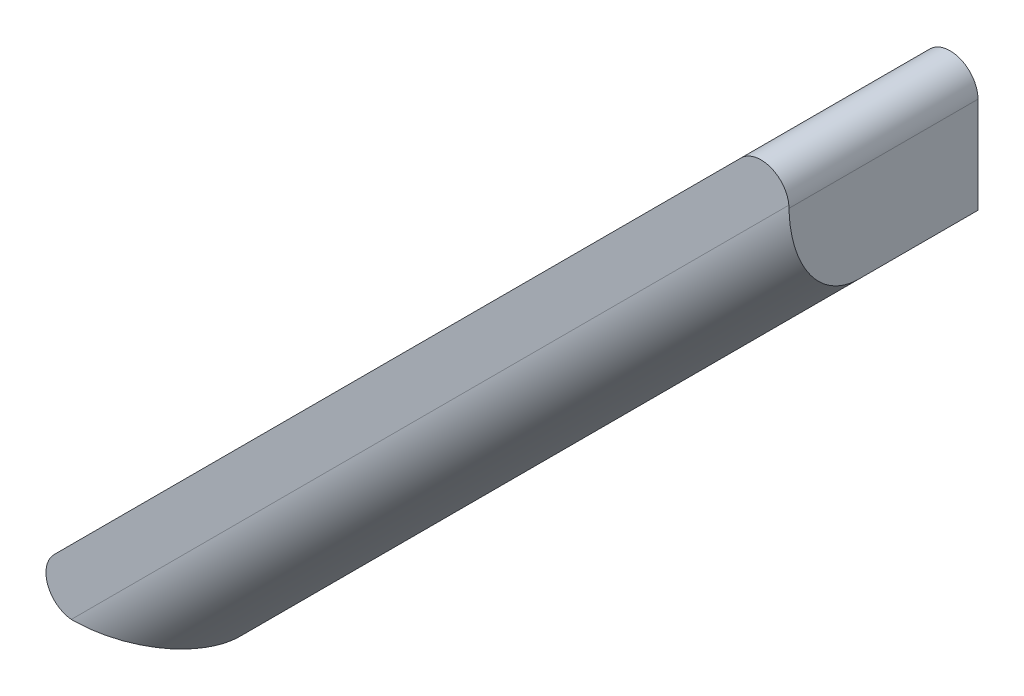
from build123d import *

# Parameters (mm, degrees)
EXTRUDE_1_DEPTH = 13.5
FILLET_1_R      = 2
FILLET_2_R      = 2
FILLET_3_R      = 5


with BuildPart() as part:
    # 草图1 → 凸台-拉伸1 (new body)
    with BuildSketch(Plane.XY):
        Polygon((0, 0), (0, -11.7), (-44.194173824, -55.894173824), (-55.894173824, -55.894173824), align=None)
    extrude(amount=EXTRUDE_1_DEPTH)

    # 圆角1
    fillet_1_edges = [part.edges().sort_by_distance(p)[0] for p in [
        (-55.894173824, -55.894173824, 6.75),
    ]]
    fillet(fillet_1_edges, radius=FILLET_1_R)

    # 圆角2
    fillet_2_edges = [part.edges().sort_by_distance(p)[0] for p in [
        (0, 0, 6.75),
    ]]
    fillet(fillet_2_edges, radius=FILLET_2_R)

    # 圆角3
    fillet_3_edges = [part.edges().sort_by_distance(p)[0] for p in [
        (-22.097086912, -33.797086912, 13.5),
    ]]
    fillet(fillet_3_edges, radius=FILLET_3_R)


solid = part.part
